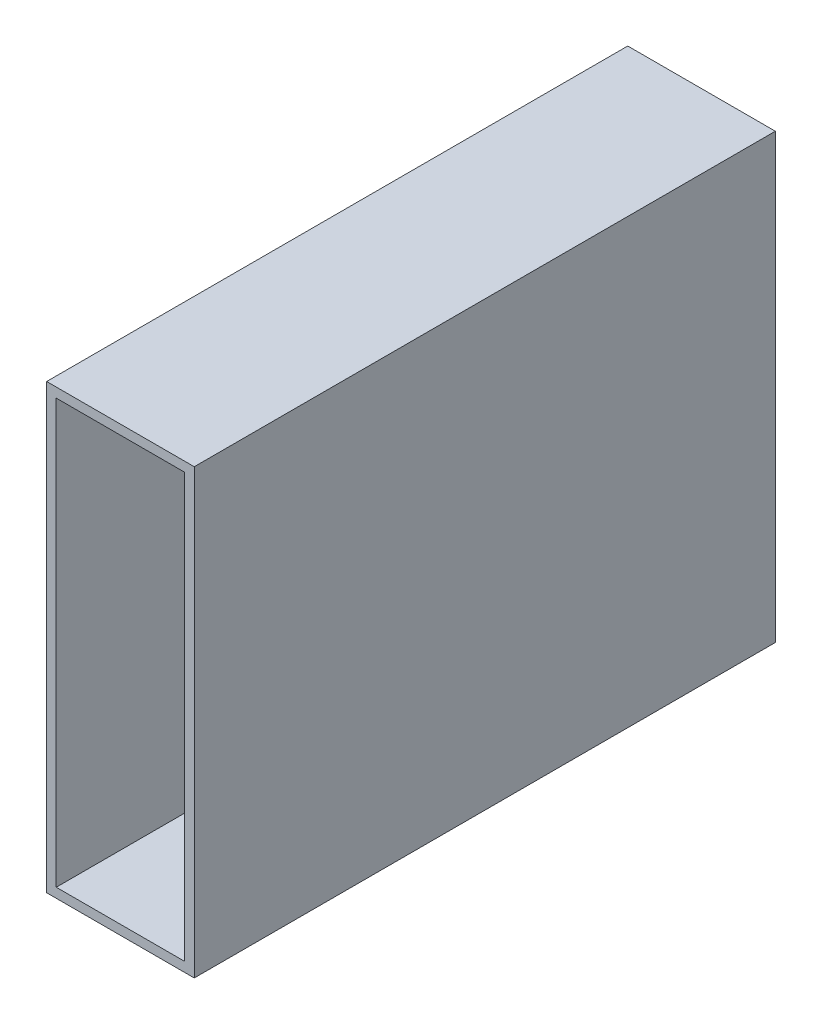
from build123d import *

# Parameters (mm, degrees)
SKETCH2_W           = 11.049
SKETCH2_H           = 1.651
SKETCH2_W_2         = 1.651
SKETCH2_H_2         = 36.449
BOSS_EXTRUDE1_DEPTH = 100


with BuildPart() as part:
    # Sketch2 → Boss-Extrude1 (new body)
    with BuildSketch(Plane.XY):
        Polygon((-12.7, 0), (-11.049, 0), (-11.049, 36.449), (-11.049, 38.1), (-12.7, 38.1), align=None)
        with Locations((-5.5245, 37.2745)):
            Rectangle(SKETCH2_W, SKETCH2_H)
        Polygon((0, 38.1), (0, 36.449), (11.049, 36.449), (11.049, 0), (12.7, 0), (12.7, 38.1), align=None)
        with Locations((11.8745, -18.2245)):
            Rectangle(SKETCH2_W_2, SKETCH2_H_2)
        Polygon((-11.049, -36.449), (-11.049, 0), (-12.7, 0), (-12.7, -38.1), (0, -38.1), (0, -36.449), align=None)
        Polygon((11.049, -36.449), (0, -36.449), (0, -38.1), (12.7, -38.1), (12.7, -36.449), align=None)
    extrude(amount=BOSS_EXTRUDE1_DEPTH)


solid = part.part
